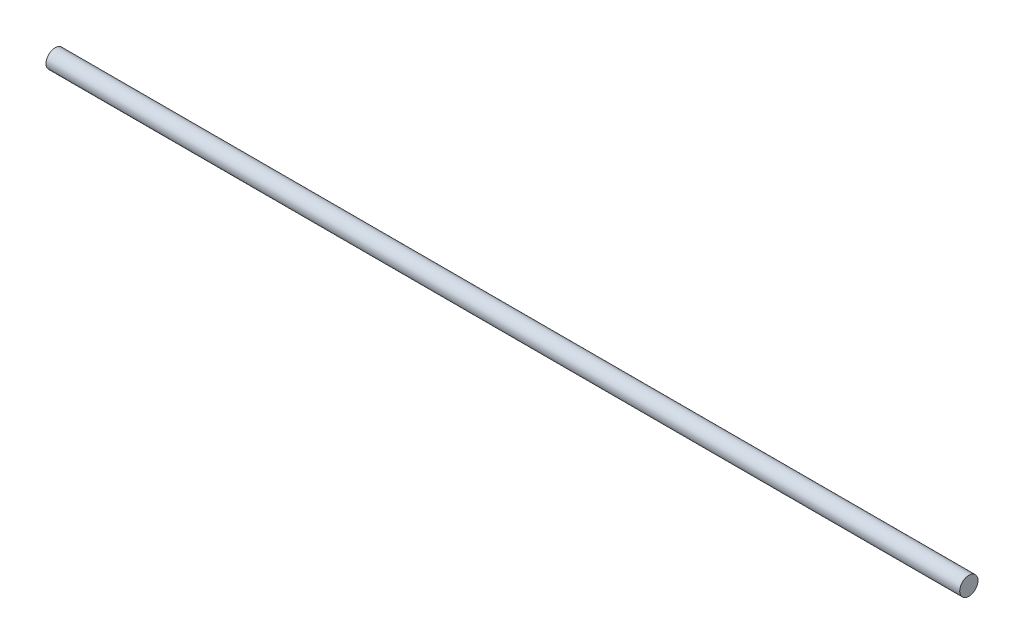
from build123d import *

# Parameters (mm, degrees)
SKETCH2_R           = 4
BOSS_EXTRUDE1_DEPTH = 400


with BuildPart() as part:
    # Sketch2 → Boss-Extrude1 (new body)
    with BuildSketch(Plane(origin=(0, 0, 0), x_dir=(0, 0, -1), z_dir=(1, 0, 0))):
        Circle(SKETCH2_R)
    extrude(amount=BOSS_EXTRUDE1_DEPTH)


solid = part.part
